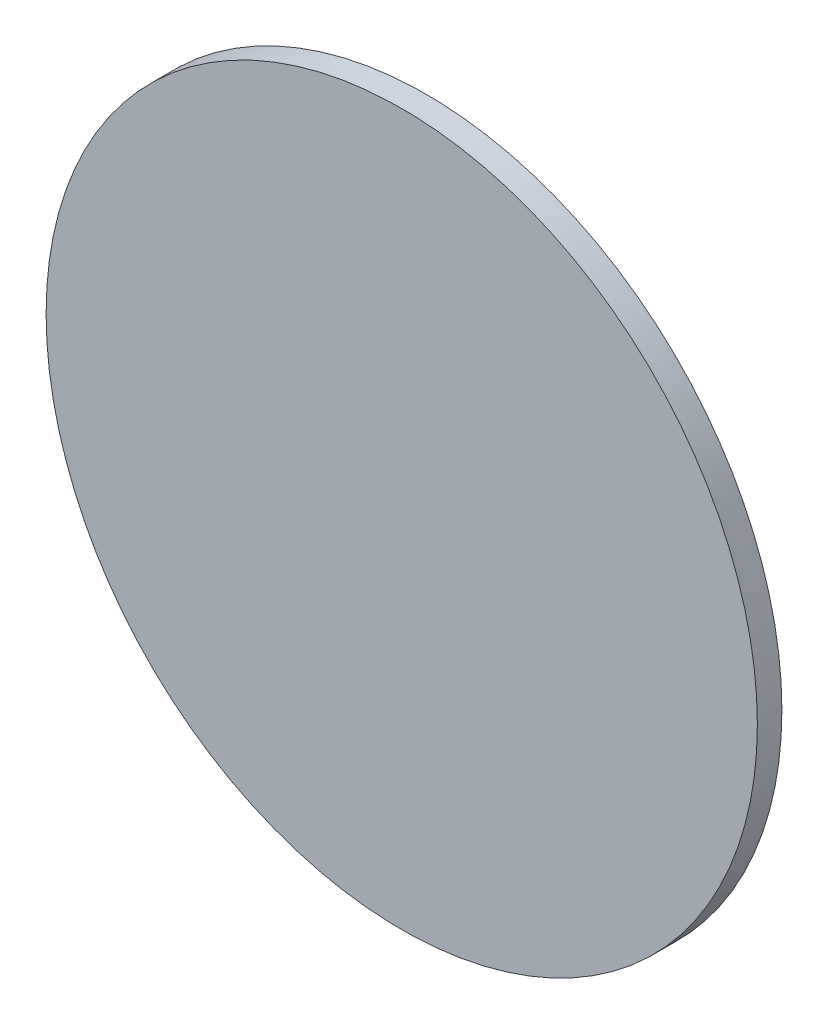
from build123d import *

# Parameters (mm, degrees)
SKETCH_1_R      = 14.5
EXTRUDE_2_DEPTH = 1


with BuildPart() as part:
    # ｽｹｯﾁ1 → ﾎﾞｽ - 押し出し2 (new body)
    with BuildSketch(Plane.XY):
        Circle(SKETCH_1_R)
    extrude(amount=EXTRUDE_2_DEPTH)


solid = part.part
